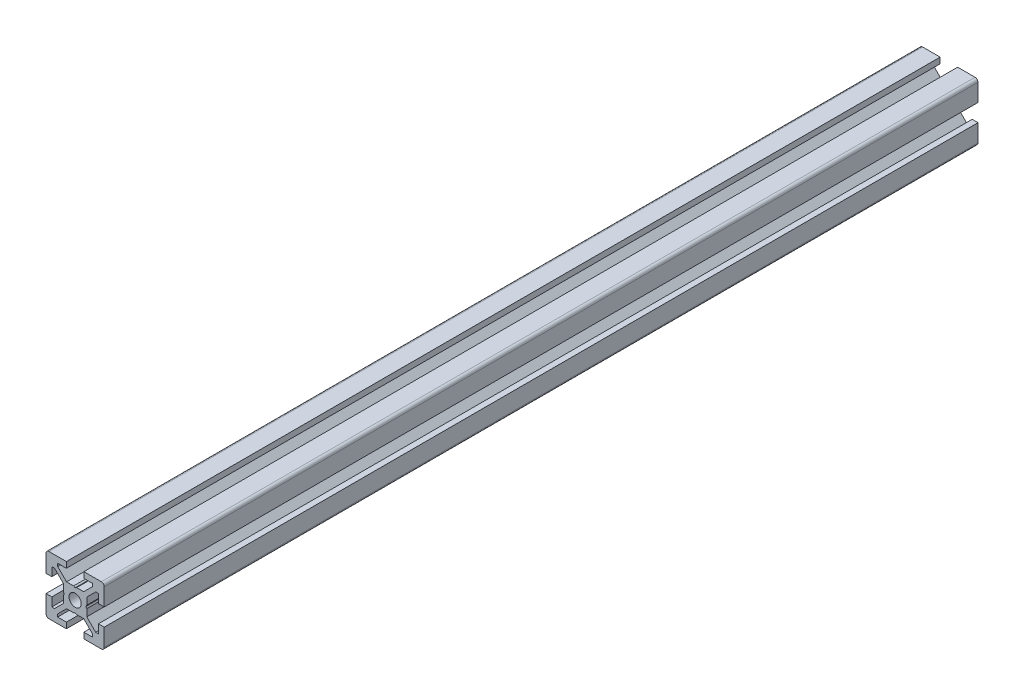
from build123d import *

# Parameters (mm, degrees)
EXTRUDE_1_DEPTH = 300
SKETCH_2_W      = 260
SKETCH_2_H      = 2.1


with BuildPart() as part:
    # ｽｹｯﾁ1 → ﾎﾞｽ - 押し出し1 (new body)
    with BuildSketch(Plane.XY):
        with BuildLine():
            Line((-10, -3), (-10, -9))
            ThreePointArc((-10, -9), (-9.707106781, -9.707106781), (-9, -10))
            Line((-9, -10), (-3, -10))
            Line((-3, -10), (-3, -8))
            Line((-3, -8), (-6, -8))
            Line((-6, -8), (-6, -7.060660172))
            Line((-6, -7.060660172), (-2.939339828, -4))
            Line((-2.939339828, -4), (-0.519615242, -4))
            Line((-0.519615242, -4), (0, -3.7))
            Line((0, -3.7), (0.519615242, -4))
            Line((0.519615242, -4), (2.939339828, -4))
            Line((2.939339828, -4), (6, -7.060660172))
            Line((6, -7.060660172), (6, -8))
            Line((6, -8), (3, -8))
            Line((3, -8), (3, -10))
            Line((3, -10), (9, -10))
            ThreePointArc((9, -10), (9.707106781, -9.707106781), (10, -9))
            Line((10, -9), (10, -3))
            Line((10, -3), (8, -3))
            Line((8, -3), (8, -6))
            Line((8, -6), (7.060660172, -6))
            Line((7.060660172, -6), (4, -2.939339828))
            Line((4, -2.939339828), (4, -0.519615242))
            Line((4, -0.519615242), (3.7, 0))
            Line((3.7, 0), (4, 0.519615242))
            Line((4, 0.519615242), (4, 2.939339828))
            Line((4, 2.939339828), (7.060660172, 6))
            Line((7.060660172, 6), (8, 6))
            Line((8, 6), (8, 3))
            Line((8, 3), (10, 3))
            Line((10, 3), (10, 9))
            ThreePointArc((10, 9), (9.707106781, 9.707106781), (9, 10))
            Line((9, 10), (3, 10))
            Line((3, 10), (3, 8))
            Line((3, 8), (6, 8))
            Line((6, 8), (6, 7.060660172))
            Line((6, 7.060660172), (2.939339828, 4))
            Line((2.939339828, 4), (0.519615242, 4))
            Line((0.519615242, 4), (0, 3.7))
            Line((0, 3.7), (-0.519615242, 4))
            Line((-0.519615242, 4), (-2.939339828, 4))
            Line((-2.939339828, 4), (-6, 7.060660172))
            Line((-6, 7.060660172), (-6, 8))
            Line((-6, 8), (-3, 8))
            Line((-3, 8), (-3, 10))
            Line((-3, 10), (-9, 10))
            ThreePointArc((-9, 10), (-9.707106781, 9.707106781), (-10, 9))
            Line((-10, 9), (-10, 3))
            Line((-10, 3), (-8, 3))
            Line((-8, 3), (-8, 6))
            Line((-8, 6), (-7.060660172, 6))
            Line((-7.060660172, 6), (-4, 2.939339828))
            Line((-4, 2.939339828), (-4, 0.519615242))
            Line((-4, 0.519615242), (-3.7, 0))
            Line((-3.7, 0), (-4, -0.519615242))
            Line((-4, -0.519615242), (-4, -2.939339828))
            Line((-4, -2.939339828), (-7.060660172, -6))
            Line((-7.060660172, -6), (-8, -6))
            Line((-8, -6), (-8, -3))
            Line((-8, -3), (-10, -3))
        make_face()
    extrude(amount=-EXTRUDE_1_DEPTH)

    # ｽｹｯﾁ2 → ｶｯﾄ - 回転1 (revolve, cut)
    with BuildSketch(Plane(origin=(0, 0, 0), x_dir=(0, 0, -1), z_dir=(1, 0, 0))):
        with Locations((130, 1.05)):
            Rectangle(SKETCH_2_W, SKETCH_2_H)
    revolve(axis=Axis((0, 0, -260), (0, 0, 1)), mode=Mode.SUBTRACT)


solid = part.part
